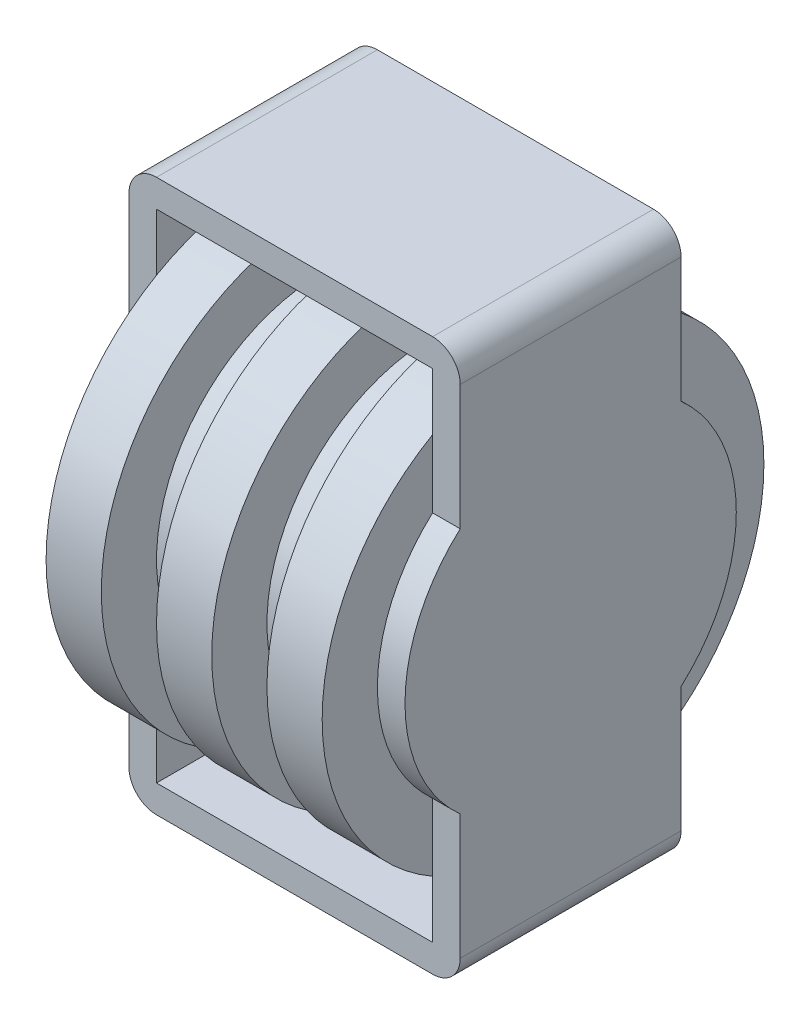
from build123d import *

# Parameters (mm, degrees)
SKETCH1_W            = 20
SKETCH1_H            = 47.5
BOSS_EXTRUDE1_DEPTH  = 2.5
SKETCH2_R            = 20
BOSS_EXTRUDE2_DEPTH  = 5
SKETCH3_R            = 15
BOSS_EXTRUDE3_DEPTH  = 5
SKETCH4_R            = 20
BOSS_EXTRUDE4_DEPTH  = 5
SKETCH5_R            = 15
BOSS_EXTRUDE5_DEPTH  = 5
SKETCH6_R            = 20
BOSS_EXTRUDE6_DEPTH  = 5
BOSS_EXTRUDE7_DEPTH  = 2.5
SKETCH8_W            = 30
SKETCH8_H            = 20
BOSS_EXTRUDE8_DEPTH  = 2.5
SKETCH10_W           = 20
SKETCH10_H           = 2.5
BOSS_EXTRUDE9_DEPTH  = 25
SKETCH11_R           = 15
BOSS_EXTRUDE10_DEPTH = 2.5
SKETCH12_R           = 15
BOSS_EXTRUDE11_DEPTH = 2.5
FILLET1_R            = 2.5
FILLET2_R            = 2.5


with BuildPart() as part:
    # Sketch1 → Boss-Extrude1 (new body)
    with BuildSketch(Plane(origin=(0, 0, 0), x_dir=(0, 0, -1), z_dir=(1, 0, 0))):
        with Locations((0, -1.25)):
            Rectangle(SKETCH1_W, SKETCH1_H)
    extrude(amount=BOSS_EXTRUDE1_DEPTH)

    # Sketch2 → Boss-Extrude2 (add)
    with BuildSketch(Plane(origin=(2.5, 0, 0), x_dir=(0, 0, -1), z_dir=(1, 0, 0))):
        Circle(SKETCH2_R)
    extrude(amount=BOSS_EXTRUDE2_DEPTH)

    # Sketch3 → Boss-Extrude3 (add)
    with BuildSketch(Plane(origin=(7.5, 0, 0), x_dir=(0, 0, -1), z_dir=(1, 0, 0))):
        Circle(SKETCH3_R)
    extrude(amount=BOSS_EXTRUDE3_DEPTH)

    # Sketch4 → Boss-Extrude4 (add)
    with BuildSketch(Plane(origin=(12.5, 0, 0), x_dir=(0, 0, -1), z_dir=(1, 0, 0))):
        Circle(SKETCH4_R)
    extrude(amount=BOSS_EXTRUDE4_DEPTH)

    # Sketch5 → Boss-Extrude5 (add)
    with BuildSketch(Plane(origin=(17.5, 0, 0), x_dir=(0, 0, -1), z_dir=(1, 0, 0))):
        Circle(SKETCH5_R)
    extrude(amount=BOSS_EXTRUDE5_DEPTH)

    # Sketch6 → Boss-Extrude6 (add)
    with BuildSketch(Plane(origin=(22.5, 0, 0), x_dir=(0, 0, -1), z_dir=(1, 0, 0))):
        Circle(SKETCH6_R)
    extrude(amount=BOSS_EXTRUDE6_DEPTH)

    # Sketch7 → Boss-Extrude7 (add)
    with BuildSketch(Plane(origin=(27.5, 0, 0), x_dir=(0, 0, -1), z_dir=(1, 0, 0))):
        Polygon((-10, -22.5), (-10, -25), (10, -25), (10, -22.5), (10, 22.5), (-10, 22.5), align=None)
    extrude(amount=BOSS_EXTRUDE7_DEPTH)

    # Sketch8 → Boss-Extrude8 (add)
    with BuildSketch(Plane(origin=(0, 22.5, 0), x_dir=(1, 0, 0), z_dir=(0, 1, 0))):
        with Locations((15, 0)):
            Rectangle(SKETCH8_W, SKETCH8_H)
    extrude(amount=BOSS_EXTRUDE8_DEPTH)

    # Sketch10 → Boss-Extrude9 (add)
    with BuildSketch(Plane(origin=(2.5, 0, 0), x_dir=(0, 0, -1), z_dir=(1, 0, 0))):
        with Locations((0, -23.75)):
            Rectangle(SKETCH10_W, SKETCH10_H)
    extrude(amount=BOSS_EXTRUDE9_DEPTH)

    # Sketch11 → Boss-Extrude10 (add)
    with BuildSketch(Plane(origin=(30, 0, 0), x_dir=(0, 0, -1), z_dir=(1, 0, 0))):
        Circle(SKETCH11_R)
    extrude(amount=-BOSS_EXTRUDE10_DEPTH)

    # Sketch12 → Boss-Extrude11 (add)
    with BuildSketch(Plane.ZY):
        Circle(SKETCH12_R)
    extrude(amount=-BOSS_EXTRUDE11_DEPTH)

    # Fillet1
    fillet1_edges = [part.edges().sort_by_distance(p)[0] for p in [
        (0, 25, 0),
        (30, 25, 0),
    ]]
    fillet(fillet1_edges, radius=FILLET1_R)

    # Fillet2
    fillet2_edges = [part.edges().sort_by_distance(p)[0] for p in [
        (30, -25, 0),
        (0, -25, 0),
    ]]
    fillet(fillet2_edges, radius=FILLET2_R)


solid = part.part
